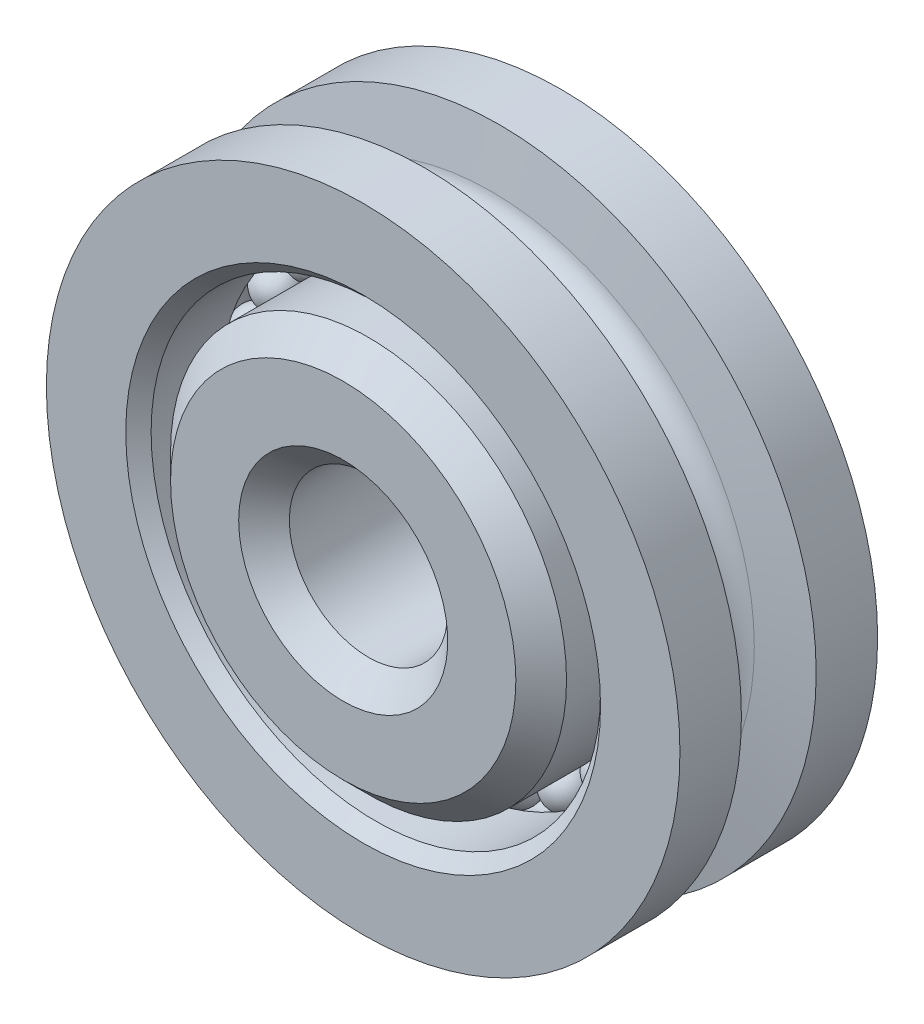
from build123d import *

# Parameters (mm, degrees)
CIRPATTERN1_COUNT = 24
CHAMFER1_SIZE     = 0.508
CHAMFER2_SIZE     = 0.254


with BuildPart() as part:
    # Sketch1 → Revolve1 (revolve)
    with BuildSketch(Plane(origin=(0, 0, 0), x_dir=(0, 0, -1), z_dir=(1, 0, 0))):
        with BuildLine():
            Line((0.7493, 6.35), (1.9812, 6.35))
            Line((1.9812, 6.35), (1.9812, 4.50453125))
            Line((1.9812, 4.50453125), (0.3571875, 4.50453125))
            ThreePointArc((0.3571875, 4.50453125), (0, 4.683125), (-0.3571875, 4.50453125))
            Line((-0.3571875, 4.50453125), (-1.9812, 4.50453125))
            Line((-1.9812, 4.50453125), (-1.9812, 6.35))
            Line((-1.9812, 6.35), (-0.7493, 6.35))
            Line((-0.7493, 6.35), (-0.588845646, 5.270303768))
            ThreePointArc((-0.588845646, 5.270303768), (0, 4.7625), (0.588845646, 5.270303768))
            Line((0.588845646, 5.270303768), (0.7493, 6.35))
        make_face()
        with BuildLine():
            Line((2.38125, 1.5875), (-2.38125, 1.5875))
            Line((-2.38125, 1.5875), (-2.38125, 3.96875))
            Line((-2.38125, 3.96875), (-0.3571875, 3.96875))
            ThreePointArc((-0.3571875, 3.96875), (0, 3.79015625), (0.3571875, 3.96875))
            Line((0.3571875, 3.96875), (2.38125, 3.96875))
            Line((2.38125, 3.96875), (2.38125, 1.5875))
        make_face()
    revolve(axis=Axis((0, 0, 2.38125), (0, 0, -1)))

    # Chamfer1
    chamfer1_edges = [part.edges().sort_by_distance(p)[0] for p in [
        (0, -3.96875, 2.38125),
        (0, -3.96875, -2.38125),
        (0, -1.5875, -2.38125),
        (0, -1.5875, 2.38125),
    ]]
    chamfer(chamfer1_edges, length=CHAMFER1_SIZE)

    # Chamfer2
    chamfer2_edges = [part.edges().sort_by_distance(p)[0] for p in [
        (0, -4.50453125, -1.9812),
        (0, -4.50453125, 1.9812),
    ]]
    chamfer(chamfer2_edges, length=CHAMFER2_SIZE)


with BuildPart() as body_2:
    # Sketch2 → Revolve2 (revolve)
    with BuildSketch(Plane(origin=(0, 0, 0), x_dir=(0, 0, -1), z_dir=(1, 0, 0))):
        with BuildLine():
            Line((0, 4.683125), (0, 3.79015625))
            ThreePointArc((0, 3.79015625), (0.446484375, 4.236640625), (0, 4.683125))
        make_face()
    revolve(axis=Axis((0, 4.683125, 0), (0, -1, 0)))


with BuildPart() as cirpattern1_1:
    # CirPattern1: pattern copy
    add(body_2.part.rotate(Axis((0, 0, 0), (0, 0, 1)), 1 * 360 / CIRPATTERN1_COUNT))


with BuildPart() as cirpattern1_2:
    # CirPattern1: pattern copy
    add(body_2.part.rotate(Axis((0, 0, 0), (0, 0, 1)), 2 * 360 / CIRPATTERN1_COUNT))


with BuildPart() as cirpattern1_3:
    # CirPattern1: pattern copy
    add(body_2.part.rotate(Axis((0, 0, 0), (0, 0, 1)), 3 * 360 / CIRPATTERN1_COUNT))


with BuildPart() as cirpattern1_4:
    # CirPattern1: pattern copy
    add(body_2.part.rotate(Axis((0, 0, 0), (0, 0, 1)), 4 * 360 / CIRPATTERN1_COUNT))


with BuildPart() as cirpattern1_5:
    # CirPattern1: pattern copy
    add(body_2.part.rotate(Axis((0, 0, 0), (0, 0, 1)), 5 * 360 / CIRPATTERN1_COUNT))


with BuildPart() as cirpattern1_6:
    # CirPattern1: pattern copy
    add(body_2.part.rotate(Axis((0, 0, 0), (0, 0, 1)), 6 * 360 / CIRPATTERN1_COUNT))


with BuildPart() as cirpattern1_7:
    # CirPattern1: pattern copy
    add(body_2.part.rotate(Axis((0, 0, 0), (0, 0, 1)), 7 * 360 / CIRPATTERN1_COUNT))


with BuildPart() as cirpattern1_8:
    # CirPattern1: pattern copy
    add(body_2.part.rotate(Axis((0, 0, 0), (0, 0, 1)), 8 * 360 / CIRPATTERN1_COUNT))


with BuildPart() as cirpattern1_9:
    # CirPattern1: pattern copy
    add(body_2.part.rotate(Axis((0, 0, 0), (0, 0, 1)), 9 * 360 / CIRPATTERN1_COUNT))


with BuildPart() as cirpattern1_10:
    # CirPattern1: pattern copy
    add(body_2.part.rotate(Axis((0, 0, 0), (0, 0, 1)), 10 * 360 / CIRPATTERN1_COUNT))


with BuildPart() as cirpattern1_11:
    # CirPattern1: pattern copy
    add(body_2.part.rotate(Axis((0, 0, 0), (0, 0, 1)), 11 * 360 / CIRPATTERN1_COUNT))


with BuildPart() as cirpattern1_12:
    # CirPattern1: pattern copy
    add(body_2.part.rotate(Axis((0, 0, 0), (0, 0, 1)), 12 * 360 / CIRPATTERN1_COUNT))


with BuildPart() as cirpattern1_13:
    # CirPattern1: pattern copy
    add(body_2.part.rotate(Axis((0, 0, 0), (0, 0, 1)), 13 * 360 / CIRPATTERN1_COUNT))


with BuildPart() as cirpattern1_14:
    # CirPattern1: pattern copy
    add(body_2.part.rotate(Axis((0, 0, 0), (0, 0, 1)), 14 * 360 / CIRPATTERN1_COUNT))


with BuildPart() as cirpattern1_15:
    # CirPattern1: pattern copy
    add(body_2.part.rotate(Axis((0, 0, 0), (0, 0, 1)), 15 * 360 / CIRPATTERN1_COUNT))


with BuildPart() as cirpattern1_16:
    # CirPattern1: pattern copy
    add(body_2.part.rotate(Axis((0, 0, 0), (0, 0, 1)), 16 * 360 / CIRPATTERN1_COUNT))


with BuildPart() as cirpattern1_17:
    # CirPattern1: pattern copy
    add(body_2.part.rotate(Axis((0, 0, 0), (0, 0, 1)), 17 * 360 / CIRPATTERN1_COUNT))


with BuildPart() as cirpattern1_18:
    # CirPattern1: pattern copy
    add(body_2.part.rotate(Axis((0, 0, 0), (0, 0, 1)), 18 * 360 / CIRPATTERN1_COUNT))


with BuildPart() as cirpattern1_19:
    # CirPattern1: pattern copy
    add(body_2.part.rotate(Axis((0, 0, 0), (0, 0, 1)), 19 * 360 / CIRPATTERN1_COUNT))


with BuildPart() as cirpattern1_20:
    # CirPattern1: pattern copy
    add(body_2.part.rotate(Axis((0, 0, 0), (0, 0, 1)), 20 * 360 / CIRPATTERN1_COUNT))


with BuildPart() as cirpattern1_21:
    # CirPattern1: pattern copy
    add(body_2.part.rotate(Axis((0, 0, 0), (0, 0, 1)), 21 * 360 / CIRPATTERN1_COUNT))


with BuildPart() as cirpattern1_22:
    # CirPattern1: pattern copy
    add(body_2.part.rotate(Axis((0, 0, 0), (0, 0, 1)), 22 * 360 / CIRPATTERN1_COUNT))


with BuildPart() as cirpattern1_23:
    # CirPattern1: pattern copy
    add(body_2.part.rotate(Axis((0, 0, 0), (0, 0, 1)), 23 * 360 / CIRPATTERN1_COUNT))


solid = Compound([part.part, body_2.part, cirpattern1_1.part, cirpattern1_2.part, cirpattern1_3.part, cirpattern1_4.part, cirpattern1_5.part, cirpattern1_6.part, cirpattern1_7.part, cirpattern1_8.part, cirpattern1_9.part, cirpattern1_10.part, cirpattern1_11.part, cirpattern1_12.part, cirpattern1_13.part, cirpattern1_14.part, cirpattern1_15.part, cirpattern1_16.part, cirpattern1_17.part, cirpattern1_18.part, cirpattern1_19.part, cirpattern1_20.part, cirpattern1_21.part, cirpattern1_22.part, cirpattern1_23.part])
